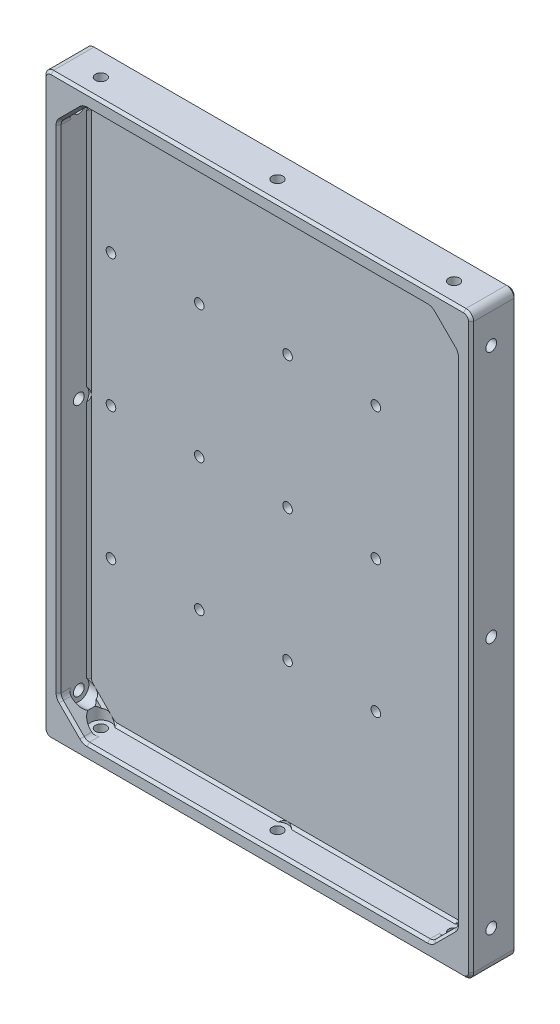
from build123d import *

# Parameters (mm, degrees)
SKETCH_1_W                   = 169.5
SKETCH_1_H                   = 229.5
EXTRUDE_1_DEPTH              = 6
SKETCH_2_W                   = 169.5
SKETCH_2_H                   = 229.5
SKETCH_2_W_2                 = 157.5
SKETCH_2_H_2                 = 217.5
EXTRUDE_2_DEPTH              = 12
CHAMFER_1_SIZE               = 10
FILLET_1_R                   = 3
CHAMFER_2_SIZE               = 1
FILLET_2_R                   = 3
CHAMFER_3_SIZE               = 1
HOLE_WIZARD_M4_1_D           = 4.3
HOLE_WIZARD_M4_1_DEPTH       = 16
HOLE_WIZARD_M4_1_CBORE_D     = 8
HOLE_WIZARD_M4_1_CBORE_DEPTH = 10
HOLE_WIZARD_M4_2_D           = 4.3
HOLE_WIZARD_M4_2_DEPTH       = 16
HOLE_WIZARD_M4_2_CBORE_D     = 8
HOLE_WIZARD_M4_2_CBORE_DEPTH = 10
HOLE_WIZARD_M4_1_2_D         = 3.8


with BuildPart() as part:
    # ｽｹｯﾁ1 → ﾎﾞｽ - 押し出し1 (new body)
    with BuildSketch(Plane.XY):
        Rectangle(SKETCH_1_W, SKETCH_1_H)
    extrude(amount=EXTRUDE_1_DEPTH)

    # ｽｹｯﾁ2 → ﾎﾞｽ - 押し出し2 (add)
    with BuildSketch(Plane.XY.offset(6)):
        Rectangle(SKETCH_2_W, SKETCH_2_H)
        Rectangle(SKETCH_2_W_2, SKETCH_2_H_2, mode=Mode.SUBTRACT)
    extrude(amount=EXTRUDE_2_DEPTH)

    # 面取り1
    chamfer_1_edges = [part.edges().sort_by_distance(p)[0] for p in [
        (-78.75, -108.75, 12),
        (78.75, -108.75, 12),
        (78.75, 108.75, 12),
        (-78.75, 108.75, 12),
    ]]
    chamfer(chamfer_1_edges, length=CHAMFER_1_SIZE)

    # ﾌｨﾚｯﾄ1
    fillet_1_edges = [part.edges().sort_by_distance(p)[0] for p in [
        (-78.75, 98.75, 12),
        (-78.75, -98.75, 12),
        (68.75, -108.75, 12),
        (-68.75, -108.75, 12),
        (78.75, 98.75, 12),
        (78.75, -98.75, 12),
        (-68.75, 108.75, 12),
        (68.75, 108.75, 12),
    ]]
    fillet(fillet_1_edges, radius=FILLET_1_R)

    # 面取り2
    chamfer_2_edges = [part.edges().sort_by_distance(p)[0] for p in [
        (0, 108.75, 6),
        (0, 108.75, 18),
        (73.75, 103.75, 18),
        (73.75, 103.75, 6),
        (-78.75, 0, 6),
        (-73.75, -103.75, 6),
        (0, -108.75, 6),
        (73.75, -103.75, 6),
        (78.75, 0, 6),
        (-73.75, 103.75, 6),
        (78.521638598, -98.65540961, 6),
        (68.65540961, -108.521638598, 6),
        (-68.65540961, -108.521638598, 6),
        (-78.521638598, -98.65540961, 6),
        (-78.521638598, 98.65540961, 6),
        (-68.65540961, 108.521638598, 6),
        (78.521638598, 98.65540961, 6),
        (68.65540961, 108.521638598, 6),
        (78.75, 0, 18),
        (-73.75, 103.75, 18),
        (-78.75, 0, 18),
        (-73.75, -103.75, 18),
        (0, -108.75, 18),
        (73.75, -103.75, 18),
        (68.65540961, 108.521638598, 18),
        (78.521638598, 98.65540961, 18),
        (-68.65540961, 108.521638598, 18),
        (-78.521638598, 98.65540961, 18),
        (-78.521638598, -98.65540961, 18),
        (-68.65540961, -108.521638598, 18),
        (68.65540961, -108.521638598, 18),
        (78.521638598, -98.65540961, 18),
    ]]
    chamfer(chamfer_2_edges, length=CHAMFER_2_SIZE)

    # ﾌｨﾚｯﾄ2
    fillet_2_edges = [part.edges().sort_by_distance(p)[0] for p in [
        (-84.75, 114.75, 9),
        (84.75, 114.75, 9),
        (84.75, -114.75, 9),
        (-84.75, -114.75, 9),
    ]]
    fillet(fillet_2_edges, radius=FILLET_2_R)

    # 面取り3
    chamfer_3_edges = [part.edges().sort_by_distance(p)[0] for p in [
        (0, 114.75, 0),
        (0, 114.75, 18),
        (-84.75, 0, 0),
        (84.75, 0, 0),
        (0, -114.75, 0),
        (-83.871320344, -113.871320344, 0),
        (83.871320344, -113.871320344, 0),
        (-83.871320344, 113.871320344, 0),
        (83.871320344, 113.871320344, 0),
        (84.75, 0, 18),
        (-84.75, 0, 18),
        (0, -114.75, 18),
        (-83.871320344, -113.871320344, 18),
        (83.871320344, -113.871320344, 18),
        (-83.871320344, 113.871320344, 18),
        (83.871320344, 113.871320344, 18),
    ]]
    chamfer(chamfer_3_edges, length=CHAMFER_3_SIZE)

    # Hole Wizard M4 _1
    with Locations(Plane(origin=(-68.75, 0, 0), x_dir=(0, 0, -1), z_dir=(1, 0, 0))):
        with Locations((-10, 0), (-10, 100), (-10, -100)):
            hole_wizard_m4_1 = CounterBoreHole(HOLE_WIZARD_M4_1_D / 2, HOLE_WIZARD_M4_1_CBORE_D / 2, HOLE_WIZARD_M4_1_CBORE_DEPTH, depth=HOLE_WIZARD_M4_1_DEPTH)

    # ﾐﾗｰ1: Hole Wizard M4 _1 across plane
    add(hole_wizard_m4_1.mirror(Plane(origin=(0, 0, 0), x_dir=(0, 0, 1), z_dir=(1, 0, 0))), mode=Mode.SUBTRACT)

    # M4 六角穴付き頭ねじ用座ぐり穴2
    with Locations(Plane(origin=(0, 98.75, 0), x_dir=(-1, 0, 0), z_dir=(0, -1, 0))):
        with Locations((-70, -10), (70, -10), (0, -10)):
            hole_wizard_m4_2 = CounterBoreHole(HOLE_WIZARD_M4_2_D / 2, HOLE_WIZARD_M4_2_CBORE_D / 2, HOLE_WIZARD_M4_2_CBORE_DEPTH, depth=HOLE_WIZARD_M4_2_DEPTH)

    # ﾐﾗｰ2: M4 六角穴付き頭ねじ用座ぐり穴2 across plane
    add(hole_wizard_m4_2.mirror(Plane.ZX), mode=Mode.SUBTRACT)

    # Hole Wizard M4 _1 2 (through all)
    with Locations(Plane(origin=(0, 0, 0), x_dir=(-1, 0, 0), z_dir=(0, 0, -1))):
        with Locations((-70, 52.5), (-70, -52.5), (-35, -52.5), (-35, 52.5), (0, 52.5), (0, -52.5), (35, -52.5), (70, -52.5), (70, 52.5), (35, 52.5), (-70, 0), (-35, 0), (0, 0), (35, 0), (70, 0)):
            Hole(HOLE_WIZARD_M4_1_2_D / 2)


solid = part.part
